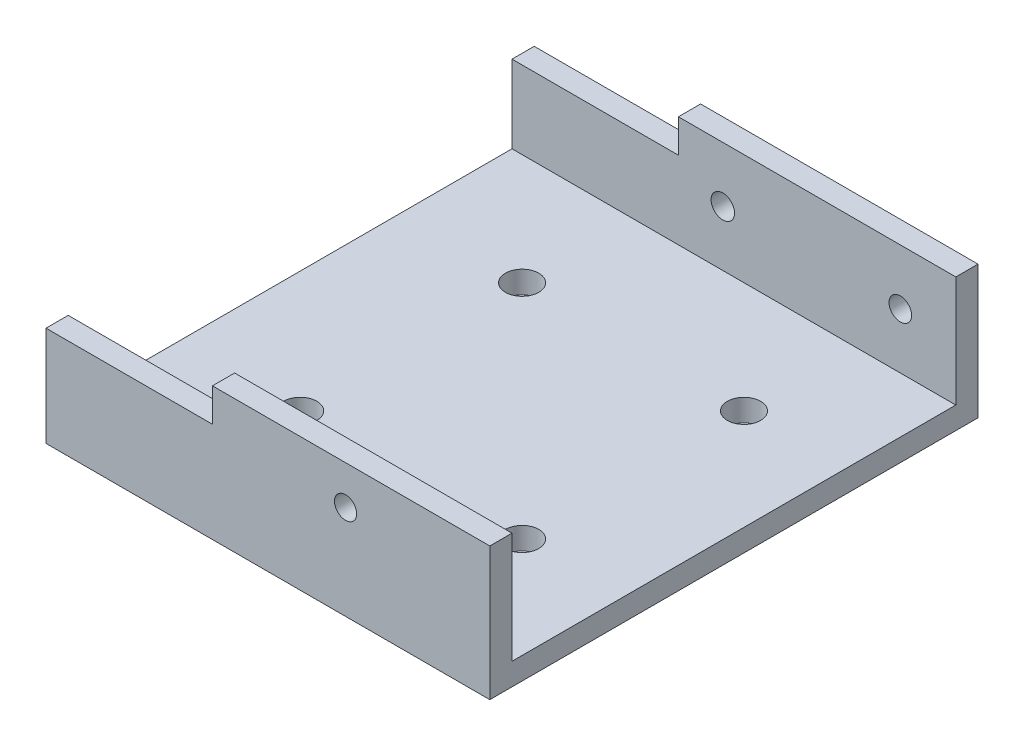
from build123d import *

# Parameters (mm, degrees)
SKETCH1_W           = 40
SKETCH1_H           = 44
BOSS_EXTRUDE1_DEPTH = 2
SKETCH2_W           = 40
SKETCH2_H           = 2
BOSS_EXTRUDE2_DEPTH = 10
SKETCH3_W           = 15
SKETCH3_H           = 3
CUT_EXTRUDE2_DEPTH  = 45
CUT_EXTRUDE3_REACH  = 4
SKETCH4_R           = 1.017178614
SKETCH4_R_2         = 1.056475415
CUT_EXTRUDE4_REACH  = 46
SKETCH5_R           = 1
CUT_EXTRUDE5_REACH  = 14
SKETCH6_R           = 1.5


with BuildPart() as part:
    # Sketch1 → Boss-Extrude1 (new body)
    with BuildSketch(Plane(origin=(0, 0, 0), x_dir=(1, 0, 0), z_dir=(0, 1, 0))):
        with Locations((20, 22)):
            Rectangle(SKETCH1_W, SKETCH1_H)
    extrude(amount=BOSS_EXTRUDE1_DEPTH)

    # Sketch2 → Boss-Extrude2 (add)
    with BuildSketch(Plane(origin=(0, 2, 0), x_dir=(1, 0, 0), z_dir=(0, 1, 0))):
        with Locations((20, 43)):
            Rectangle(SKETCH2_W, SKETCH2_H)
        with Locations((20, 1)):
            Rectangle(SKETCH2_W, SKETCH2_H)
    extrude(amount=BOSS_EXTRUDE2_DEPTH)

    # Sketch3 → Cut-Extrude2 (cut, through all)
    with BuildSketch(Plane(origin=(0, 0, -44), x_dir=(-1, 0, 0), z_dir=(0, 0, -1))):
        with Locations((-7.5, 10.5)):
            Rectangle(SKETCH3_W, SKETCH3_H)
    extrude(amount=-CUT_EXTRUDE2_DEPTH, mode=Mode.SUBTRACT)

    # Sketch4 → Cut-Extrude3 (cut, up to next)
    with BuildSketch(Plane(origin=(0, 0, -42), x_dir=(-1, 0, 0), z_dir=(0, 0, -1)), mode=Mode.PRIVATE) as cut_extrude3_sk1:
        with Locations((-35, 7)):
            Circle(SKETCH4_R)
    cut_extrude3_tool1 = extrude(cut_extrude3_sk1.sketch, amount=CUT_EXTRUDE3_REACH, mode=Mode.PRIVATE) & part.part
    add(cut_extrude3_tool1.solids().sort_by_distance((35, 7, -42))[0], mode=Mode.SUBTRACT)
    # Sketch4 → Cut-Extrude3 (cut, up to next)
    with BuildSketch(Plane(origin=(0, 0, -42), x_dir=(-1, 0, 0), z_dir=(0, 0, -1)), mode=Mode.PRIVATE) as cut_extrude3_sk2:
        with Locations((-19, 7)):
            Circle(SKETCH4_R_2)
    cut_extrude3_tool2 = extrude(cut_extrude3_sk2.sketch, amount=CUT_EXTRUDE3_REACH, mode=Mode.PRIVATE) & part.part
    add(cut_extrude3_tool2.solids().sort_by_distance((19, 7, -42))[0], mode=Mode.SUBTRACT)

    # Sketch5 → Cut-Extrude4 (cut, up to next)
    with BuildSketch(Plane.XY, mode=Mode.PRIVATE) as cut_extrude4_sk1:
        with Locations((27, 8.5)):
            Circle(SKETCH5_R)
    cut_extrude4_tool1 = extrude(cut_extrude4_sk1.sketch, amount=-CUT_EXTRUDE4_REACH, mode=Mode.PRIVATE) & part.part
    add(cut_extrude4_tool1.solids().sort_by_distance((27, 8.5, 0))[0], mode=Mode.SUBTRACT)

    # Sketch6 → Cut-Extrude5 (cut, up to next)
    with BuildSketch(Plane.XZ, mode=Mode.PRIVATE) as cut_extrude5_sk1:
        with Locations((10.909090909, -32)):
            Circle(SKETCH6_R)
    cut_extrude5_tool1 = extrude(cut_extrude5_sk1.sketch, amount=-CUT_EXTRUDE5_REACH, mode=Mode.PRIVATE) & part.part
    add(cut_extrude5_tool1.solids().sort_by_distance((10.909091, 0, -32))[0], mode=Mode.SUBTRACT)
    # Sketch6 → Cut-Extrude5 (cut, up to next)
    with BuildSketch(Plane.XZ, mode=Mode.PRIVATE) as cut_extrude5_sk2:
        with Locations((10.909090909, -12)):
            Circle(SKETCH6_R)
    cut_extrude5_tool2 = extrude(cut_extrude5_sk2.sketch, amount=-CUT_EXTRUDE5_REACH, mode=Mode.PRIVATE) & part.part
    add(cut_extrude5_tool2.solids().sort_by_distance((10.909091, 0, -12))[0], mode=Mode.SUBTRACT)
    # Sketch6 → Cut-Extrude5 (cut, up to next)
    with BuildSketch(Plane.XZ, mode=Mode.PRIVATE) as cut_extrude5_sk3:
        with Locations((30.909090909, -12)):
            Circle(SKETCH6_R)
    cut_extrude5_tool3 = extrude(cut_extrude5_sk3.sketch, amount=-CUT_EXTRUDE5_REACH, mode=Mode.PRIVATE) & part.part
    add(cut_extrude5_tool3.solids().sort_by_distance((30.909091, 0, -12))[0], mode=Mode.SUBTRACT)
    # Sketch6 → Cut-Extrude5 (cut, up to next)
    with BuildSketch(Plane.XZ, mode=Mode.PRIVATE) as cut_extrude5_sk4:
        with Locations((30.909090909, -32)):
            Circle(SKETCH6_R)
    cut_extrude5_tool4 = extrude(cut_extrude5_sk4.sketch, amount=-CUT_EXTRUDE5_REACH, mode=Mode.PRIVATE) & part.part
    add(cut_extrude5_tool4.solids().sort_by_distance((30.909091, 0, -32))[0], mode=Mode.SUBTRACT)


solid = part.part
